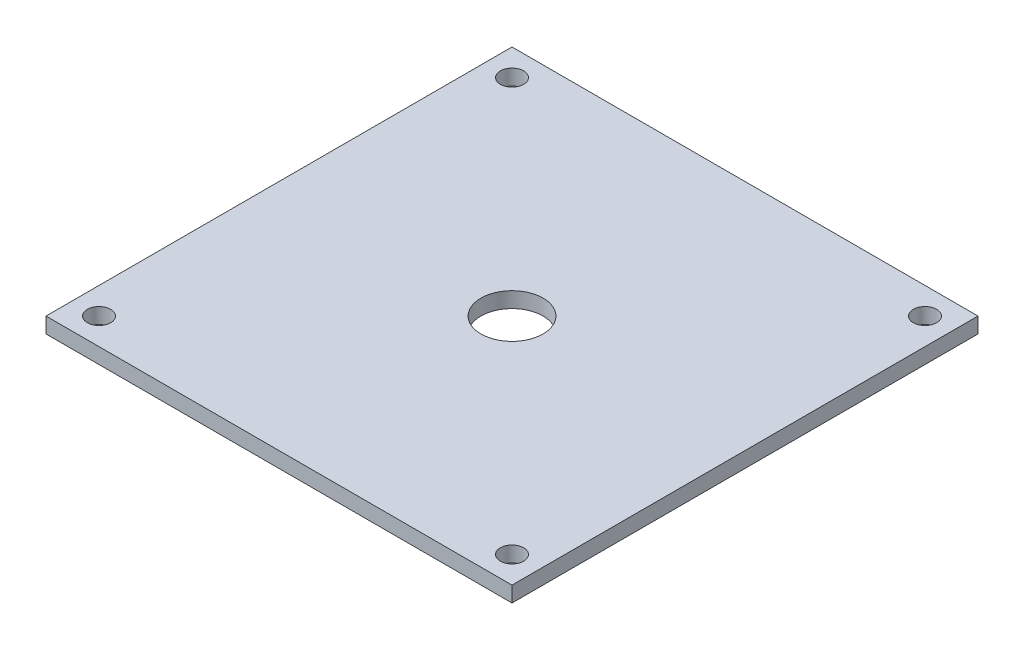
from build123d import *

# Parameters (mm, degrees)
CROQUIS1_W              = 300
CROQUIS1_H              = 300
CROQUIS1_R              = 20
CROQUIS1_R_2            = 7.5
SALIENTE_EXTRUIR1_DEPTH = 10


with BuildPart() as part:
    # Croquis1 → Saliente-Extruir1 (new body)
    with BuildSketch(Plane(origin=(0, 0, 0), x_dir=(1, 0, 0), z_dir=(0, 1, 0))):
        Rectangle(CROQUIS1_W, CROQUIS1_H)
        Circle(CROQUIS1_R, mode=Mode.SUBTRACT)
        with Locations((-132.936074863, 132.936074863)):
            Circle(CROQUIS1_R_2, mode=Mode.SUBTRACT)
        with Locations((132.936074863, 132.936074863)):
            Circle(CROQUIS1_R_2, mode=Mode.SUBTRACT)
        with Locations((132.936074863, -132.936074863)):
            Circle(CROQUIS1_R_2, mode=Mode.SUBTRACT)
        with Locations((-132.936074863, -132.936074863)):
            Circle(CROQUIS1_R_2, mode=Mode.SUBTRACT)
    extrude(amount=SALIENTE_EXTRUIR1_DEPTH)


solid = part.part
